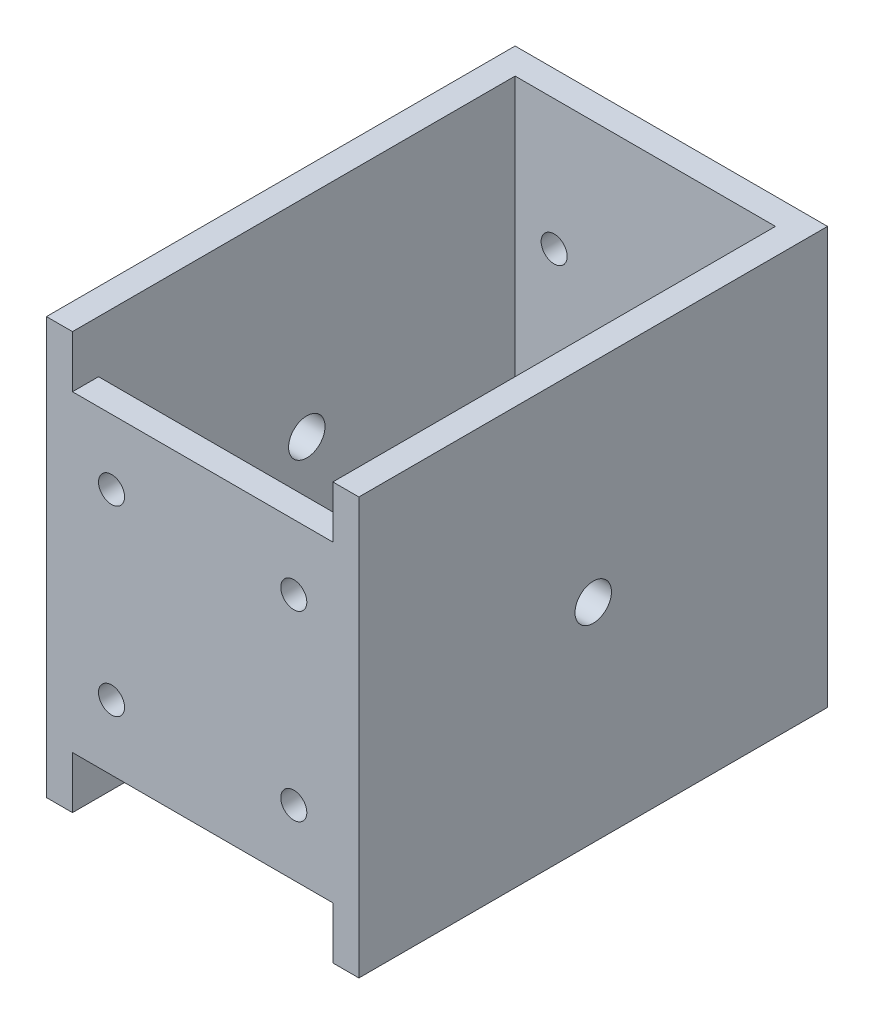
from build123d import *

# Parameters (mm, degrees)
SKETCH1_W           = 60
SKETCH1_H           = 80
BOSS_EXTRUDE1_DEPTH = 80
SKETCH2_W           = 50
SKETCH2_H           = 75
CUT_EXTRUDE1_DEPTH  = 80
SKETCH3_R           = 2.5
CUT_EXTRUDE2_DEPTH  = 60
SKETCH4_R           = 3.5
CUT_EXTRUDE3_DEPTH  = 80
SKETCH5_W           = 5
SKETCH5_H           = 80
BOSS_EXTRUDE2_DEPTH = 5
SKETCH6_W           = 60
SKETCH6_H           = 80
BOSS_EXTRUDE3_DEPTH = 5
SKETCH7_R           = 2.5
CUT_EXTRUDE4_DEPTH  = 5
SKETCH8_W           = 50
SKETCH8_H           = 10
CUT_EXTRUDE5_DEPTH  = 5


with BuildPart() as part:
    # Sketch1 → Boss-Extrude1 (new body)
    with BuildSketch(Plane.XY):
        Rectangle(SKETCH1_W, SKETCH1_H)
    extrude(amount=BOSS_EXTRUDE1_DEPTH)

    # Sketch2 → Cut-Extrude1 (cut)
    with BuildSketch(Plane(origin=(0, 40, 0), x_dir=(1, 0, 0), z_dir=(0, 1, 0))):
        with Locations((0, -42.5)):
            Rectangle(SKETCH2_W, SKETCH2_H)
    extrude(amount=-CUT_EXTRUDE1_DEPTH, mode=Mode.SUBTRACT)

    # Sketch3 → Cut-Extrude2 (cut)
    with BuildSketch(Plane(origin=(0, 0, 0), x_dir=(-1, 0, 0), z_dir=(0, 0, -1))):
        with Locations((-17.5, 15)):
            Circle(SKETCH3_R)
        with Locations((17.5, 15)):
            Circle(SKETCH3_R)
        with Locations((-17.5, -20)):
            Circle(SKETCH3_R)
        with Locations((17.5, -20)):
            Circle(SKETCH3_R)
    extrude(amount=-CUT_EXTRUDE2_DEPTH, mode=Mode.SUBTRACT)

    # Sketch4 → Cut-Extrude3 (cut)
    with BuildSketch(Plane(origin=(30, 0, 0), x_dir=(0, 0, -1), z_dir=(1, 0, 0))):
        with Locations((-45, 0)):
            Circle(SKETCH4_R)
    extrude(amount=-CUT_EXTRUDE3_DEPTH, mode=Mode.SUBTRACT)

    # Sketch5 → Boss-Extrude2 (add)
    with BuildSketch(Plane.XY.offset(80)):
        with Locations((-27.5, 0)):
            Rectangle(SKETCH5_W, SKETCH5_H)
        with Locations((27.5, 0)):
            Rectangle(SKETCH5_W, SKETCH5_H)
    extrude(amount=BOSS_EXTRUDE2_DEPTH)

    # Sketch6 → Boss-Extrude3 (add)
    with BuildSketch(Plane.XY.offset(85)):
        Rectangle(SKETCH6_W, SKETCH6_H)
    extrude(amount=BOSS_EXTRUDE3_DEPTH)

    # Sketch7 → Cut-Extrude4 (cut)
    with BuildSketch(Plane.XY.offset(90)):
        with Locations((-17.5, 17.5)):
            Circle(SKETCH7_R)
        with Locations((17.5, 17.5)):
            Circle(SKETCH7_R)
        with Locations((17.5, -17.5)):
            Circle(SKETCH7_R)
        with Locations((-17.5, -17.5)):
            Circle(SKETCH7_R)
    extrude(amount=-CUT_EXTRUDE4_DEPTH, mode=Mode.SUBTRACT)

    # Sketch8 → Cut-Extrude5 (cut)
    with BuildSketch(Plane.XY.offset(90)):
        with Locations((0, 35)):
            Rectangle(SKETCH8_W, SKETCH8_H)
        with Locations((0, -35)):
            Rectangle(SKETCH8_W, SKETCH8_H)
    extrude(amount=-CUT_EXTRUDE5_DEPTH, mode=Mode.SUBTRACT)


solid = part.part
